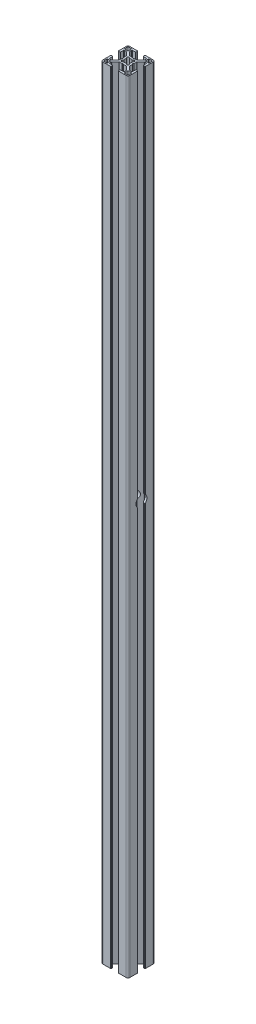
from build123d import *

# Parameters (mm, degrees)
EXTRUDE1_DEPTH          = 4000
SKETCH3_W               = 61.599419231
SKETCH3_H               = 4322.791301462
CUT_EXTRUDE3_DEPTH      = 10.165268255
CUT_EXTRUDE3_DEPTH_BACK = 21.834611745
SKETCH7_R               = 6.1
CUT_EXTRUDE4_DEPTH      = 10.165268255
CUT_EXTRUDE4_DEPTH_BACK = 21.834611745


with BuildPart() as part:
    # Sketch1 → Extrude1 (new body)
    with BuildSketch(Plane(origin=(0, 0, 0), x_dir=(1, 0, 0), z_dir=(0, 1, 0))):
        with BuildLine():
            Line((300.053103973, -32.880446014), (300.053103973, -36.112965336))
            ThreePointArc((300.053103973, -36.112965336), (299.91307902, -36.47774281), (299.553410558, -36.630413014))
            Line((299.553410558, -36.630413014), (297.570817355, -36.630413014))
            ThreePointArc((297.570817355, -36.630413014), (297.379476404, -36.592352933), (297.217265379, -36.48396699))
            Line((297.217265379, -36.48396699), (293.291747091, -32.558448703))
            ThreePointArc((293.291747091, -32.558448703), (293.183361149, -32.396237678), (293.145301068, -32.204896727))
            Line((293.145301068, -32.204896727), (293.145301068, -29.392941964))
            Line((293.145301068, -29.392941964), (292.635303108, -28.442945764))
            Line((292.635303108, -28.442945764), (293.145301068, -27.492949564))
            Line((293.145301068, -27.492949564), (293.145301068, -24.555995301))
            ThreePointArc((293.145301068, -24.555995301), (293.183361149, -24.36465435), (293.291747091, -24.202443325))
            Line((293.291747091, -24.202443325), (297.217265379, -20.276925038))
            ThreePointArc((297.217265379, -20.276925038), (297.379476404, -20.168539096), (297.570817355, -20.130479014))
            Line((297.570817355, -20.130479014), (299.553410558, -20.130479014))
            ThreePointArc((299.553410558, -20.130479014), (299.91307902, -20.283149218), (300.053103973, -20.647926693))
            Line((300.053103973, -20.647926693), (300.053103973, -23.880446014))
            ThreePointArc((300.053103973, -23.880446014), (300.199550583, -24.233999405), (300.553103973, -24.380446014))
            Line((300.553103973, -24.380446014), (301.810569323, -24.380446014))
            ThreePointArc((301.810569323, -24.380446014), (302.164122713, -24.233999405), (302.310569323, -23.880446014))
            Line((302.310569323, -23.880446014), (302.310569323, -15.380498014))
            ThreePointArc((302.310569323, -15.380498014), (301.724785228, -13.966290108), (300.310577323, -13.380506014))
            Line((300.310577323, -13.380506014), (291.810629323, -13.380506014))
            ThreePointArc((291.810629323, -13.380506014), (291.457075932, -13.526952623), (291.310629323, -13.880506014))
            Line((291.310629323, -13.880506014), (291.310629323, -15.137971364))
            ThreePointArc((291.310629323, -15.137971364), (291.457075932, -15.491524754), (291.810629323, -15.637971364))
            Line((291.810629323, -15.637971364), (295.043148644, -15.637971364))
            ThreePointArc((295.043148644, -15.637971364), (295.407926119, -15.777996317), (295.560596323, -16.137664778))
            Line((295.560596323, -16.137664778), (295.560596323, -18.120257982))
            ThreePointArc((295.560596323, -18.120257982), (295.522536241, -18.311598933), (295.414150299, -18.473809958))
            Line((295.414150299, -18.473809958), (291.488632012, -22.399328245))
            ThreePointArc((291.488632012, -22.399328245), (291.326420986, -22.507714187), (291.135080036, -22.545774269))
            Line((291.135080036, -22.545774269), (288.260625523, -22.545774269))
            Line((288.260625523, -22.545774269), (287.310629323, -23.055772229))
            Line((287.310629323, -23.055772229), (286.360633123, -22.545774269))
            Line((286.360633123, -22.545774269), (283.48617861, -22.545774269))
            ThreePointArc((283.48617861, -22.545774269), (283.294837659, -22.507714187), (283.132626634, -22.399328245))
            Line((283.132626634, -22.399328245), (279.207108346, -18.473809958))
            ThreePointArc((279.207108346, -18.473809958), (279.098722404, -18.311598933), (279.060662323, -18.120257982))
            Line((279.060662323, -18.120257982), (279.060662323, -16.137664778))
            ThreePointArc((279.060662323, -16.137664778), (279.213332527, -15.777996317), (279.578110001, -15.637971364))
            Line((279.578110001, -15.637971364), (282.810629323, -15.637971364))
            ThreePointArc((282.810629323, -15.637971364), (283.164182713, -15.491524754), (283.310629323, -15.137971364))
            Line((283.310629323, -15.137971364), (283.310629323, -13.880506014))
            ThreePointArc((283.310629323, -13.880506014), (283.164182713, -13.526952623), (282.810629323, -13.380506014))
            Line((282.810629323, -13.380506014), (274.310681323, -13.380506014))
            ThreePointArc((274.310681323, -13.380506014), (272.896473417, -13.966290108), (272.310689323, -15.380498014))
            Line((272.310689323, -15.380498014), (272.310689323, -23.880446014))
            ThreePointArc((272.310689323, -23.880446014), (272.457135932, -24.233999405), (272.810689323, -24.380446014))
            Line((272.810689323, -24.380446014), (274.068154672, -24.380446014))
            ThreePointArc((274.068154672, -24.380446014), (274.421708063, -24.233999405), (274.568154672, -23.880446014))
            Line((274.568154672, -23.880446014), (274.568154672, -20.647926693))
            ThreePointArc((274.568154672, -20.647926693), (274.708179626, -20.283149218), (275.067848087, -20.130479014))
            Line((275.067848087, -20.130479014), (277.05044129, -20.130479014))
            ThreePointArc((277.05044129, -20.130479014), (277.241782241, -20.168539096), (277.403993267, -20.276925038))
            Line((277.403993267, -20.276925038), (281.329511554, -24.202443325))
            ThreePointArc((281.329511554, -24.202443325), (281.437897496, -24.36465435), (281.475957578, -24.555995301))
            Line((281.475957578, -24.555995301), (281.475957578, -27.492949564))
            Line((281.475957578, -27.492949564), (281.985955538, -28.442945764))
            Line((281.985955538, -28.442945764), (281.475957578, -29.392941964))
            Line((281.475957578, -29.392941964), (281.475957578, -32.204896727))
            ThreePointArc((281.475957578, -32.204896727), (281.437897496, -32.396237678), (281.329511554, -32.558448703))
            Line((281.329511554, -32.558448703), (277.403993267, -36.48396699))
            ThreePointArc((277.403993267, -36.48396699), (277.241782241, -36.592352933), (277.05044129, -36.630413014))
            Line((277.05044129, -36.630413014), (275.067848087, -36.630413014))
            ThreePointArc((275.067848087, -36.630413014), (274.708179626, -36.47774281), (274.568154672, -36.112965336))
            Line((274.568154672, -36.112965336), (274.568154672, -32.880446014))
            ThreePointArc((274.568154672, -32.880446014), (274.421708063, -32.526892623), (274.068154672, -32.380446014))
            Line((274.068154672, -32.380446014), (272.810689323, -32.380446014))
            ThreePointArc((272.810689323, -32.380446014), (272.457135932, -32.526892623), (272.310689323, -32.880446014))
            Line((272.310689323, -32.880446014), (272.310689323, -41.380394014))
            ThreePointArc((272.310689323, -41.380394014), (272.896473417, -42.79460192), (274.310681323, -43.380386014))
            Line((274.310681323, -43.380386014), (282.810629323, -43.380386014))
            ThreePointArc((282.810629323, -43.380386014), (283.164182713, -43.233939405), (283.310629323, -42.880386014))
            Line((283.310629323, -42.880386014), (283.310629323, -41.622920664))
            ThreePointArc((283.310629323, -41.622920664), (283.164182713, -41.269367274), (282.810629323, -41.122920664))
            Line((282.810629323, -41.122920664), (279.578110001, -41.122920664))
            ThreePointArc((279.578110001, -41.122920664), (279.213332527, -40.982895711), (279.060662323, -40.62322725))
            Line((279.060662323, -40.62322725), (279.060662323, -38.640634046))
            ThreePointArc((279.060662323, -38.640634046), (279.098722404, -38.449293096), (279.207108346, -38.28708207))
            Line((279.207108346, -38.28708207), (283.132626634, -34.361563783))
            ThreePointArc((283.132626634, -34.361563783), (283.294837659, -34.253177841), (283.48617861, -34.215117759))
            Line((283.48617861, -34.215117759), (286.360633123, -34.215117759))
            Line((286.360633123, -34.215117759), (287.310629323, -33.705119799))
            Line((287.310629323, -33.705119799), (288.260625523, -34.215117759))
            Line((288.260625523, -34.215117759), (291.135080036, -34.215117759))
            ThreePointArc((291.135080036, -34.215117759), (291.326420986, -34.253177841), (291.488632012, -34.361563783))
            Line((291.488632012, -34.361563783), (295.414150299, -38.28708207))
            ThreePointArc((295.414150299, -38.28708207), (295.522536241, -38.449293096), (295.560596323, -38.640634046))
            Line((295.560596323, -38.640634046), (295.560596323, -40.62322725))
            ThreePointArc((295.560596323, -40.62322725), (295.407926119, -40.982895711), (295.043148644, -41.122920664))
            Line((295.043148644, -41.122920664), (291.810629323, -41.122920664))
            ThreePointArc((291.810629323, -41.122920664), (291.457075932, -41.269367274), (291.310629323, -41.622920664))
            Line((291.310629323, -41.622920664), (291.310629323, -42.880386014))
            ThreePointArc((291.310629323, -42.880386014), (291.457075932, -43.233939405), (291.810629323, -43.380386014))
            Line((291.810629323, -43.380386014), (300.310577323, -43.380386014))
            ThreePointArc((300.310577323, -43.380386014), (301.724785228, -42.79460192), (302.310569323, -41.380394014))
            Line((302.310569323, -41.380394014), (302.310569323, -32.880446014))
            ThreePointArc((302.310569323, -32.880446014), (302.164122713, -32.526892623), (301.810569323, -32.380446014))
            Line((301.810569323, -32.380446014), (300.553103973, -32.380446014))
            ThreePointArc((300.553103973, -32.380446014), (300.199550583, -32.526892623), (300.053103973, -32.880446014))
        make_face()
        with BuildLine():
            Line((296.810591323, -41.699392738), (296.810591323, -38.260406494))
            ThreePointArc((296.810591323, -38.260406494), (296.921890301, -37.991706992), (297.190589803, -37.880408014))
            Line((297.190589803, -37.880408014), (300.629576047, -37.880408014))
            ThreePointArc((300.629576047, -37.880408014), (300.898982653, -37.991999884), (301.010574523, -38.26140649))
            Line((301.010574523, -38.26140649), (301.010574523, -41.080395214))
            ThreePointArc((301.010574523, -41.080395214), (300.717682476, -41.787499167), (300.010578523, -42.080391214))
            Line((300.010578523, -42.080391214), (297.191589799, -42.080391214))
            ThreePointArc((297.191589799, -42.080391214), (296.922183193, -41.968799344), (296.810591323, -41.699392738))
        make_face(mode=Mode.SUBTRACT)
        with BuildLine():
            Line((273.991682599, -37.880408014), (277.430668843, -37.880408014))
            ThreePointArc((277.430668843, -37.880408014), (277.699368345, -37.991706992), (277.810667323, -38.260406494))
            Line((277.810667323, -38.260406494), (277.810667323, -41.699392738))
            ThreePointArc((277.810667323, -41.699392738), (277.699075453, -41.968799344), (277.429668847, -42.080391214))
            Line((277.429668847, -42.080391214), (274.610680123, -42.080391214))
            ThreePointArc((274.610680123, -42.080391214), (273.90357617, -41.787499167), (273.610684123, -41.080395214))
            Line((273.610684123, -41.080395214), (273.610684123, -38.26140649))
            ThreePointArc((273.610684123, -38.26140649), (273.722275993, -37.991999884), (273.991682599, -37.880408014))
        make_face(mode=Mode.SUBTRACT)
        with BuildLine():
            Line((285.816404075, -31.578584726), (284.8372875, -32.36037316))
            ThreePointArc((284.8372875, -32.36037316), (283.410401622, -32.280673715), (283.330702177, -30.853787837))
            Line((283.330702177, -30.853787837), (284.112490611, -29.874671262))
            ThreePointArc((284.112490611, -29.874671262), (283.780643443, -28.380446014), (284.112490611, -26.886220766))
            Line((284.112490611, -26.886220766), (283.330702177, -25.907104192))
            ThreePointArc((283.330702177, -25.907104192), (283.410401622, -24.480218313), (284.8372875, -24.400518869))
            Line((284.8372875, -24.400518869), (285.816404075, -25.182307302))
            ThreePointArc((285.816404075, -25.182307302), (287.310629323, -24.850460134), (288.804854571, -25.182307302))
            Line((288.804854571, -25.182307302), (289.783971145, -24.400518869))
            ThreePointArc((289.783971145, -24.400518869), (291.210857024, -24.480218313), (291.290556468, -25.907104192))
            Line((291.290556468, -25.907104192), (290.508768035, -26.886220766))
            ThreePointArc((290.508768035, -26.886220766), (290.840615203, -28.380446014), (290.508768035, -29.874671262))
            Line((290.508768035, -29.874671262), (291.290556468, -30.853787837))
            ThreePointArc((291.290556468, -30.853787837), (291.210857024, -32.280673715), (289.783971145, -32.36037316))
            Line((289.783971145, -32.36037316), (288.804854571, -31.578584726))
            ThreePointArc((288.804854571, -31.578584726), (287.310629323, -31.910431894), (285.816404075, -31.578584726))
        make_face(mode=Mode.SUBTRACT)
        with BuildLine():
            Line((277.810667323, -15.06149929), (277.810667323, -18.500485534))
            ThreePointArc((277.810667323, -18.500485534), (277.699368345, -18.769185036), (277.430668843, -18.880484014))
            Line((277.430668843, -18.880484014), (273.991682599, -18.880484014))
            ThreePointArc((273.991682599, -18.880484014), (273.722275993, -18.768892144), (273.610684123, -18.499485538))
            Line((273.610684123, -18.499485538), (273.610684123, -15.680496814))
            ThreePointArc((273.610684123, -15.680496814), (273.90357617, -14.973392861), (274.610680123, -14.680500814))
            Line((274.610680123, -14.680500814), (277.429668847, -14.680500814))
            ThreePointArc((277.429668847, -14.680500814), (277.699075453, -14.792092684), (277.810667323, -15.06149929))
        make_face(mode=Mode.SUBTRACT)
        with BuildLine():
            Line((297.191589799, -14.680500814), (300.010578523, -14.680500814))
            ThreePointArc((300.010578523, -14.680500814), (300.717682476, -14.973392861), (301.010574523, -15.680496814))
            Line((301.010574523, -15.680496814), (301.010574523, -18.499485538))
            ThreePointArc((301.010574523, -18.499485538), (300.898982653, -18.768892144), (300.629576047, -18.880484014))
            Line((300.629576047, -18.880484014), (297.190589803, -18.880484014))
            ThreePointArc((297.190589803, -18.880484014), (296.921890301, -18.769185036), (296.810591323, -18.500485534))
            Line((296.810591323, -18.500485534), (296.810591323, -15.06149929))
            ThreePointArc((296.810591323, -15.06149929), (296.922183193, -14.792092684), (297.191589799, -14.680500814))
        make_face(mode=Mode.SUBTRACT)
    extrude(amount=EXTRUDE1_DEPTH)

    # Sketch3 → Cut-Extrude3 (cut, two sides)
    with BuildSketch(Plane(origin=(293.145301068, 0, 0), x_dir=(0, 0, -1), z_dir=(1, 0, 0))) as cut_extrude3_sk:
        with Locations((-14.662893931, 968.604349269)):
            Rectangle(SKETCH3_W, SKETCH3_H)
    extrude(amount=CUT_EXTRUDE3_DEPTH, mode=Mode.SUBTRACT)
    extrude(cut_extrude3_sk.sketch, amount=-CUT_EXTRUDE3_DEPTH_BACK, mode=Mode.SUBTRACT)

    # Sketch7 → Cut-Extrude4 (cut, two sides)
    with BuildSketch(Plane(origin=(293.145301068, 0, 0), x_dir=(0, 0, -1), z_dir=(1, 0, 0))) as cut_extrude4_sk:
        with Locations((-28.442945764, 3583.109881272)):
            Circle(SKETCH7_R)
    extrude(amount=CUT_EXTRUDE4_DEPTH, mode=Mode.SUBTRACT)
    extrude(cut_extrude4_sk.sketch, amount=-CUT_EXTRUDE4_DEPTH_BACK, mode=Mode.SUBTRACT)


solid = part.part
